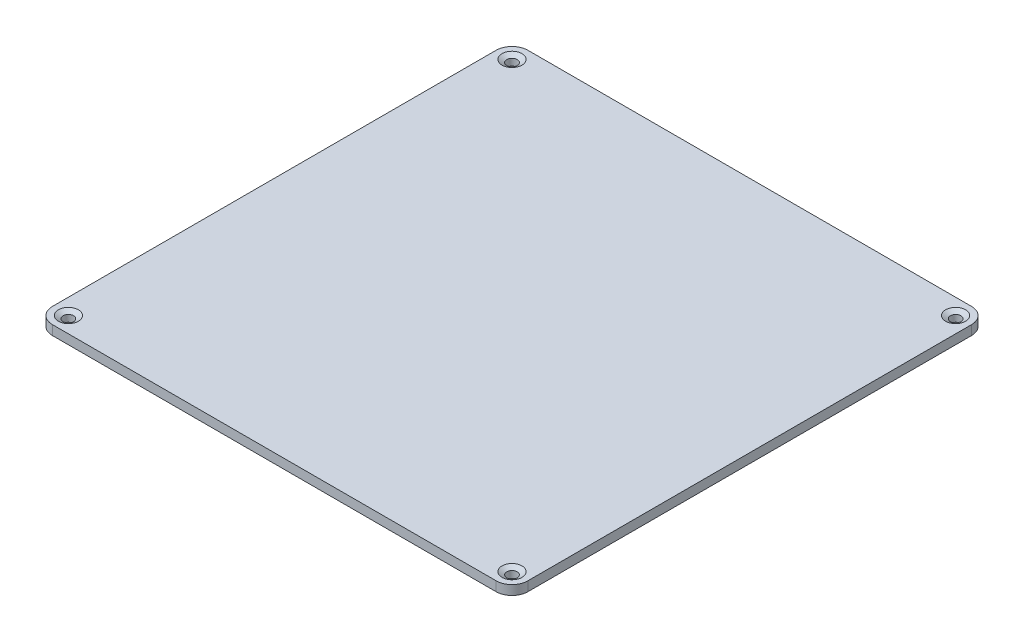
from build123d import *

# Parameters (mm, degrees)
SKETCH1_W           = 150
SKETCH1_H           = 150
BOSS_EXTRUDE1_DEPTH = 3
CUT_EXTRUDE1_REACH  = 5
SKETCH2_R           = 1.65
CHAMFER1_SIZE       = 1.5
CHAMFER1_SIZE2      = 0.866025404
FILLET1_R           = 5


with BuildPart() as part:
    # Sketch1 → Boss-Extrude1 (new body)
    with BuildSketch(Plane(origin=(0, 0, 0), x_dir=(1, 0, 0), z_dir=(0, 1, 0))):
        Rectangle(SKETCH1_W, SKETCH1_H)
    extrude(amount=BOSS_EXTRUDE1_DEPTH)

    # Sketch2 → Cut-Extrude1 (cut, up to next)
    with BuildSketch(Plane(origin=(0, 3, 0), x_dir=(1, 0, 0), z_dir=(0, 1, 0)), mode=Mode.PRIVATE) as cut_extrude1_sk1:
        with Locations((-70, 70)):
            Circle(SKETCH2_R)
    cut_extrude1_tool1 = extrude(cut_extrude1_sk1.sketch, amount=-CUT_EXTRUDE1_REACH, mode=Mode.PRIVATE) & part.part
    add(cut_extrude1_tool1.solids().sort_by_distance((-70, 3, -70))[0], mode=Mode.SUBTRACT)
    # Sketch2 → Cut-Extrude1 (cut, up to next)
    with BuildSketch(Plane(origin=(0, 3, 0), x_dir=(1, 0, 0), z_dir=(0, 1, 0)), mode=Mode.PRIVATE) as cut_extrude1_sk2:
        with Locations((70, 70)):
            Circle(SKETCH2_R)
    cut_extrude1_tool2 = extrude(cut_extrude1_sk2.sketch, amount=-CUT_EXTRUDE1_REACH, mode=Mode.PRIVATE) & part.part
    add(cut_extrude1_tool2.solids().sort_by_distance((70, 3, -70))[0], mode=Mode.SUBTRACT)
    # Sketch2 → Cut-Extrude1 (cut, up to next)
    with BuildSketch(Plane(origin=(0, 3, 0), x_dir=(1, 0, 0), z_dir=(0, 1, 0)), mode=Mode.PRIVATE) as cut_extrude1_sk3:
        with Locations((70, -70)):
            Circle(SKETCH2_R)
    cut_extrude1_tool3 = extrude(cut_extrude1_sk3.sketch, amount=-CUT_EXTRUDE1_REACH, mode=Mode.PRIVATE) & part.part
    add(cut_extrude1_tool3.solids().sort_by_distance((70, 3, 70))[0], mode=Mode.SUBTRACT)
    # Sketch2 → Cut-Extrude1 (cut, up to next)
    with BuildSketch(Plane(origin=(0, 3, 0), x_dir=(1, 0, 0), z_dir=(0, 1, 0)), mode=Mode.PRIVATE) as cut_extrude1_sk4:
        with Locations((-70, -70)):
            Circle(SKETCH2_R)
    cut_extrude1_tool4 = extrude(cut_extrude1_sk4.sketch, amount=-CUT_EXTRUDE1_REACH, mode=Mode.PRIVATE) & part.part
    add(cut_extrude1_tool4.solids().sort_by_distance((-70, 3, 70))[0], mode=Mode.SUBTRACT)

    # Chamfer1
    chamfer1_edges = [part.edges().sort_by_distance(p)[0] for p in [
        (-71.65, 3, 70),
        (68.35, 3, 70),
        (68.35, 3, -70),
        (-71.65, 3, -70),
    ]]
    chamfer1_side = [part.faces().sort_by_distance(p)[0] for p in [
        (0, 3, 0),
    ]]
    chamfer(chamfer1_edges, length=CHAMFER1_SIZE, length2=CHAMFER1_SIZE2, reference=chamfer1_side[0])

    # Fillet1
    fillet1_edges = [part.edges().sort_by_distance(p)[0] for p in [
        (75, 1.5, 75),
        (-75, 1.5, 75),
        (-75, 1.5, -75),
        (75, 1.5, -75),
    ]]
    fillet(fillet1_edges, radius=FILLET1_R)


solid = part.part
